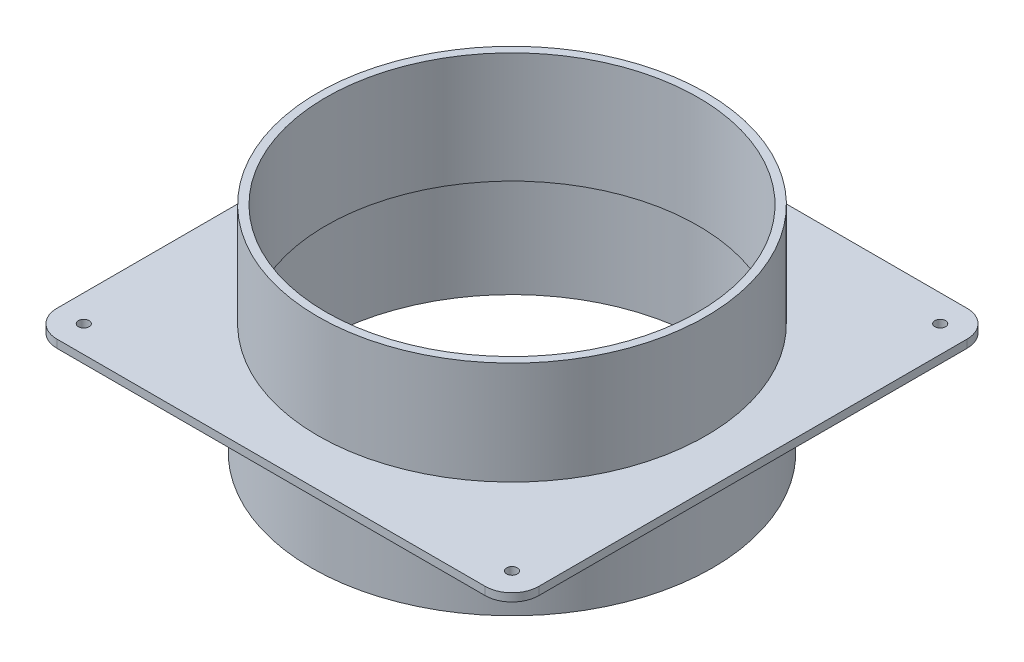
from build123d import *

# Parameters (mm, degrees)
BOSS_EXTRUDE3_DEPTH      = 1.5
BOSS_EXTRUDE3_DEPTH_BACK = 1.5
SKETCH1_R                = 2
SKETCH1_R_2              = 69.5
SKETCH2_R                = 72.5
SKETCH2_R_2              = 69.5
BOSS_EXTRUDE4_DEPTH      = 40
SKETCH4_R                = 75
SKETCH4_R_2              = 72
BOSS_EXTRUDE6_DEPTH      = 40


with BuildPart() as part:
    # Sketch1 → Boss-Extrude3 (new, two sides: drawn at the far end of the back side and taken through both)
    with BuildSketch(Plane(origin=(0, 0, 0), x_dir=(1, 0, 0), z_dir=(0, 1, 0)).offset(-BOSS_EXTRUDE3_DEPTH_BACK)):
        with BuildLine():
            ThreePointArc((90, 80), (87.071067812, 87.071067812), (80, 90))
            Line((80, 90), (-80, 90))
            ThreePointArc((-80, 90), (-87.071067812, 87.071067812), (-90, 80))
            Line((-90, 80), (-90, -80))
            ThreePointArc((-90, -80), (-87.071067812, -87.071067812), (-80, -90))
            Line((-80, -90), (80, -90))
            ThreePointArc((80, -90), (87.071067812, -87.071067812), (90, -80))
            Line((90, -80), (90, 80))
        make_face()
        with Locations((-80, -80)):
            Circle(SKETCH1_R, mode=Mode.SUBTRACT)
        with Locations((80, -80)):
            Circle(SKETCH1_R, mode=Mode.SUBTRACT)
        Circle(SKETCH1_R_2, mode=Mode.SUBTRACT)
        with Locations((-80, 80)):
            Circle(SKETCH1_R, mode=Mode.SUBTRACT)
        with Locations((80, 80)):
            Circle(SKETCH1_R, mode=Mode.SUBTRACT)
    extrude(amount=BOSS_EXTRUDE3_DEPTH + BOSS_EXTRUDE3_DEPTH_BACK)

    # Sketch2 → Boss-Extrude4 (add)
    with BuildSketch(Plane(origin=(0, 0, 0), x_dir=(1, 0, 0), z_dir=(0, 1, 0))):
        Circle(SKETCH2_R)
        Circle(SKETCH2_R_2, mode=Mode.SUBTRACT)
    extrude(amount=BOSS_EXTRUDE4_DEPTH)

    # Sketch4 → Boss-Extrude6 (add)
    with BuildSketch(Plane(origin=(0, 0, 0), x_dir=(1, 0, 0), z_dir=(0, 1, 0))):
        Circle(SKETCH4_R)
        Circle(SKETCH4_R_2, mode=Mode.SUBTRACT)
    extrude(amount=-BOSS_EXTRUDE6_DEPTH)


solid = part.part
